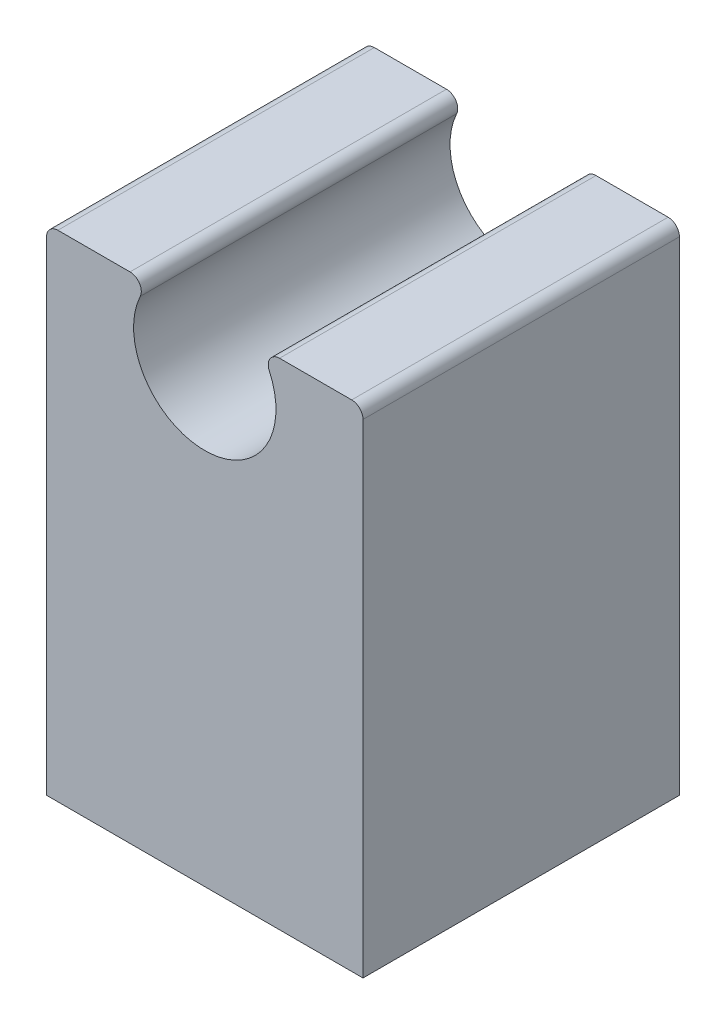
from build123d import *

# Parameters (mm, degrees)
BOSS_EXTRUDE1_DEPTH = 11.1125
SKETCH2_W           = 22.225
SKETCH2_H           = 22.225
BOSS_EXTRUDE2_DEPTH = 1.524


with BuildPart() as part:
    # Sketch1 → Boss-Extrude1 (new body, symmetric)
    with BuildSketch(Plane.XY):
        with BuildLine():
            Line((-11.1125, 2.448544554), (-11.1125, -30))
            Line((-11.1125, -30), (0, -30))
            Line((0, -30), (0, -5))
            ThreePointArc((0, -5), (-4.216957229, -2.686498042), (-4.531538935, 2.113091309))
            ThreePointArc((-4.531538935, 2.113091309), (-4.581478781, 2.875026118), (-5.250920741, 3.242294554))
            Line((-5.250920741, 3.242294554), (-10.31875, 3.242294554))
            ThreePointArc((-10.31875, 3.242294554), (-10.880016008, 3.009810562), (-11.1125, 2.448544554))
        make_face()
    boss_extrude1 = extrude(amount=BOSS_EXTRUDE1_DEPTH, both=True)

    # Mirror1: Boss-Extrude1 across plane
    add(boss_extrude1.mirror(Plane(origin=(0, 0, 0), x_dir=(0, 0, 1), z_dir=(1, 0, 0))))

    # Sketch2 → Boss-Extrude2 (add)
    with BuildSketch(Plane.XZ.offset(30)):
        Rectangle(SKETCH2_W, SKETCH2_H)
    extrude(amount=BOSS_EXTRUDE2_DEPTH)


solid = part.part
